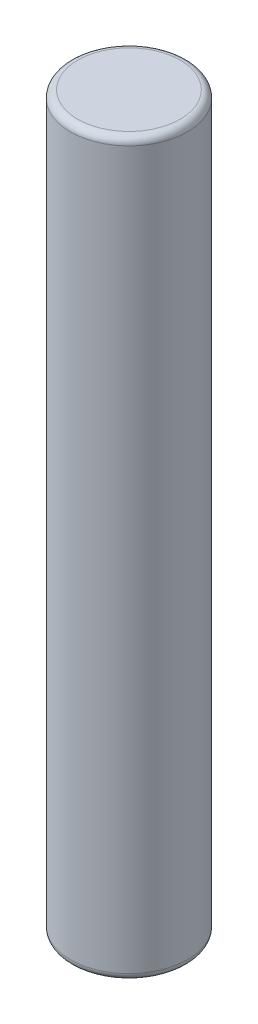
from build123d import *

# Parameters (mm, degrees)
SKETCH1_R           = 4
BOSS_EXTRUDE1_DEPTH = 50
FILLET1_R           = 0.5


with BuildPart() as part:
    # Sketch1 → Boss-Extrude1 (new body)
    with BuildSketch(Plane(origin=(0, 0, 0), x_dir=(1, 0, 0), z_dir=(0, 1, 0))):
        Circle(SKETCH1_R)
    extrude(amount=BOSS_EXTRUDE1_DEPTH)

    # Fillet1
    fillet1_edges = [part.edges().sort_by_distance(p)[0] for p in [
        (-4, 0, 0),
        (-4, 50, 0),
    ]]
    fillet(fillet1_edges, radius=FILLET1_R)


solid = part.part
